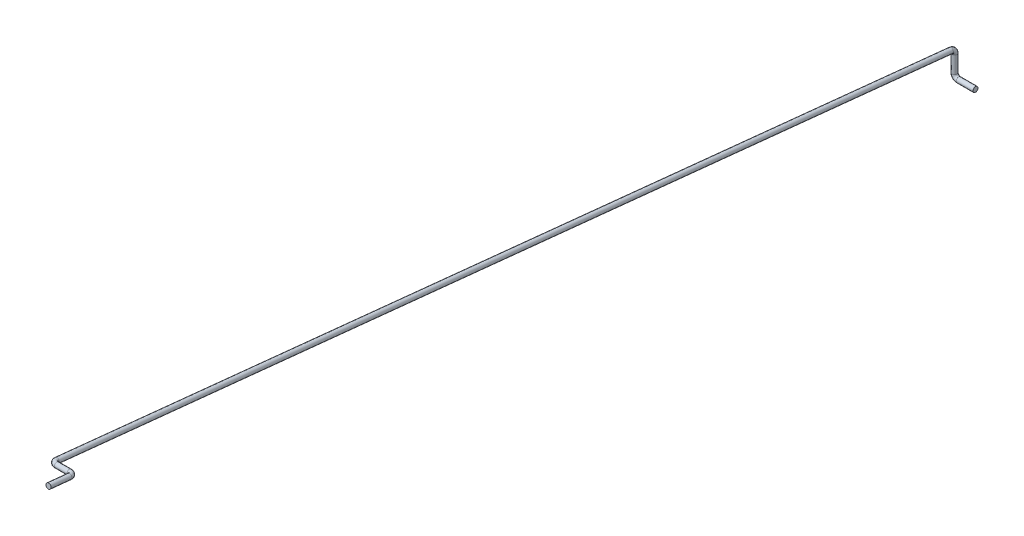
from build123d import *

# Parameters (mm, degrees)
SKETCH2_R  = 0.6
SKETCH6_R  = 0.6
SKETCH10_R = 0.6


with BuildPart() as part:
    # Sweep1: sweep along a path in Sketch1
    with BuildLine(Plane(origin=(0, 0, 0), x_dir=(0, 0, -1), z_dir=(1, 0, 0))) as sweep1_path:
        Line((0, 0), (0, 2))
        ThreePointArc((0, 2), (-0.257625253, 2.669984877), (-0.897759471, 2.994759707))
        Line((-0.897759471, 2.994759707), (-214.005240293, 24.897759471))
    # Sketch2 → Sweep1 (sweep)
    with BuildSketch(Plane(origin=(0, 0, 0), x_dir=(1, 0, 0), z_dir=(0, 1, 0))):
        Circle(SKETCH2_R)
    sweep(path=sweep1_path.line)

    # Sweep3: sweep along a path in Sketch4
    with BuildLine(Plane.XY) as sweep3_path:
        Line((0, 0), (0, -2))
        ThreePointArc((0, -2), (0.292893219, -2.707106781), (1, -3))
        Line((1, -3), (5, -3))
    # Sketch6 → Sweep3 (sweep)
    with BuildSketch(Plane.XZ):
        Circle(SKETCH6_R)
    sweep(path=sweep3_path.line)

    # Sweep4: sweep along a path in Sketch9
    with BuildLine(Plane(origin=(0, 2.872148696, -0.295196921), x_dir=(1, 0, 0), z_dir=(0, -0.994759707, 0.102240529))) as sweep4_path:
        Line((5, 222.429350183), (5, 217.429350183))
        ThreePointArc((5, 217.429350183), (4.707106781, 216.722243402), (4, 216.429350183))
        Line((4, 216.429350183), (1, 216.429350183))
        ThreePointArc((1, 216.429350183), (0.292893219, 216.136456964), (0, 215.429350183))
    # Sketch10 → Sweep4 (sweep)
    with BuildSketch(Plane(origin=(0, 22.025610775, 214.300437214), x_dir=(1, 0, 0), z_dir=(0, 0.102240529, 0.994759707))):
        with Locations((0, 2.887278884)):
            Circle(SKETCH10_R)
    sweep(path=sweep4_path.line)


solid = part.part
